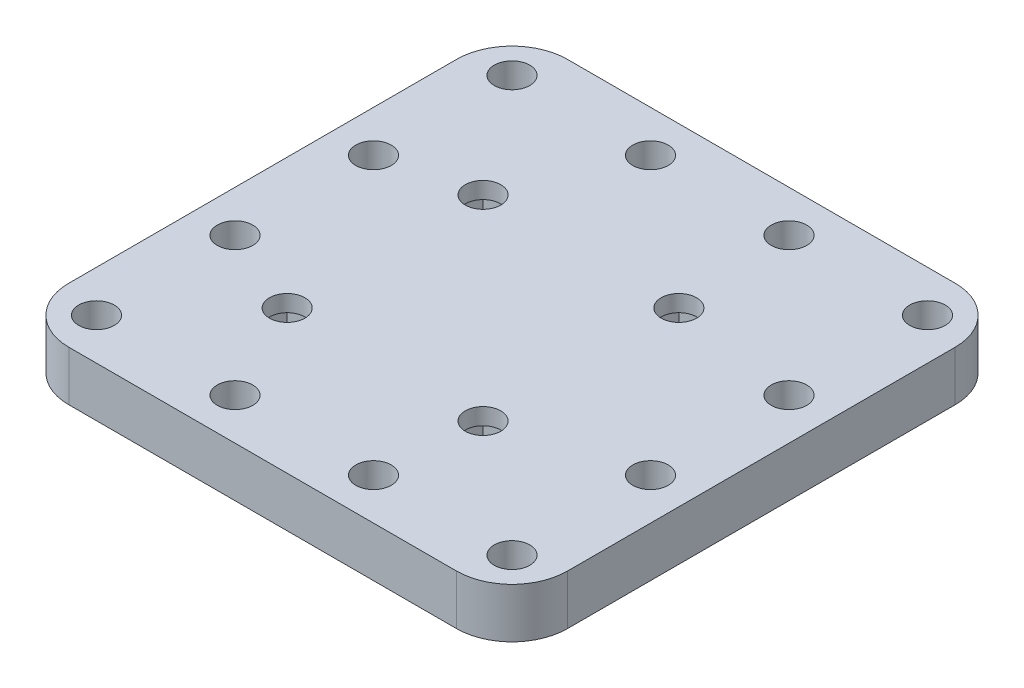
from build123d import *

# Parameters (mm, degrees)
SKETCH_1_W          = 90
SKETCH_1_H          = 90
SKETCH_1_R          = 3.2
EXTRUDE_1_DEPTH     = 9
SKETCH_2_W          = 10.3
SKETCH_2_H          = 10.3
CUT_EXTRUDE_1_DEPTH = 6
FILLET_1_R          = 10


with BuildPart() as part:
    # 스케치1 → 보스-돌출1 (new body)
    with BuildSketch(Plane(origin=(0, 0, 0), x_dir=(1, 0, 0), z_dir=(0, 1, 0))):
        with Locations((12.5, 12.5)):
            Rectangle(SKETCH_1_W, SKETCH_1_H)
        with Locations((-8.92766953, 28.6979618)):
            Circle(SKETCH_1_R, mode=Mode.SUBTRACT)
        with Locations((26.42766953, 28.6979618)):
            Circle(SKETCH_1_R, mode=Mode.SUBTRACT)
        with Locations((-8.92766953, -6.65737726)):
            Circle(SKETCH_1_R, mode=Mode.SUBTRACT)
        with Locations((26.42766953, -6.65737726)):
            Circle(SKETCH_1_R, mode=Mode.SUBTRACT)
        with Locations((25, -25)):
            Circle(SKETCH_1_R, mode=Mode.SUBTRACT)
        with Locations((50, 25)):
            Circle(SKETCH_1_R, mode=Mode.SUBTRACT)
        with Locations((50, -25)):
            Circle(SKETCH_1_R, mode=Mode.SUBTRACT)
        with Locations((0, -25)):
            Circle(SKETCH_1_R, mode=Mode.SUBTRACT)
        with Locations((50, 50)):
            Circle(SKETCH_1_R, mode=Mode.SUBTRACT)
        with Locations((-25, 50)):
            Circle(SKETCH_1_R, mode=Mode.SUBTRACT)
        with Locations((-25, -25)):
            Circle(SKETCH_1_R, mode=Mode.SUBTRACT)
        with Locations((-25, 25)):
            Circle(SKETCH_1_R, mode=Mode.SUBTRACT)
        with Locations((-25, 0)):
            Circle(SKETCH_1_R, mode=Mode.SUBTRACT)
        with Locations((50, 0)):
            Circle(SKETCH_1_R, mode=Mode.SUBTRACT)
        with Locations((25, 50)):
            Circle(SKETCH_1_R, mode=Mode.SUBTRACT)
        with Locations((0, 50)):
            Circle(SKETCH_1_R, mode=Mode.SUBTRACT)
    extrude(amount=EXTRUDE_1_DEPTH)

    # 스케치2 → 컷-돌출1 (cut)
    with BuildSketch(Plane.XZ):
        with Locations((-8.92766953, 6.65737726)):
            Rectangle(SKETCH_2_W, SKETCH_2_H)
        with Locations((26.42766953, 6.65737726)):
            Rectangle(SKETCH_2_W, SKETCH_2_H)
        with Locations((26.42766953, -28.6979618)):
            Rectangle(SKETCH_2_W, SKETCH_2_H)
        with Locations((-8.92766953, -28.6979618)):
            Rectangle(SKETCH_2_W, SKETCH_2_H)
    extrude(amount=-CUT_EXTRUDE_1_DEPTH, mode=Mode.SUBTRACT)

    # 필렛1
    fillet_1_edges = [part.edges().sort_by_distance(p)[0] for p in [
        (-32.5, 4.5, 32.5),
        (-32.5, 4.5, -57.5),
        (57.5, 4.5, -57.5),
        (57.5, 4.5, 32.5),
    ]]
    fillet(fillet_1_edges, radius=FILLET_1_R)


solid = part.part
